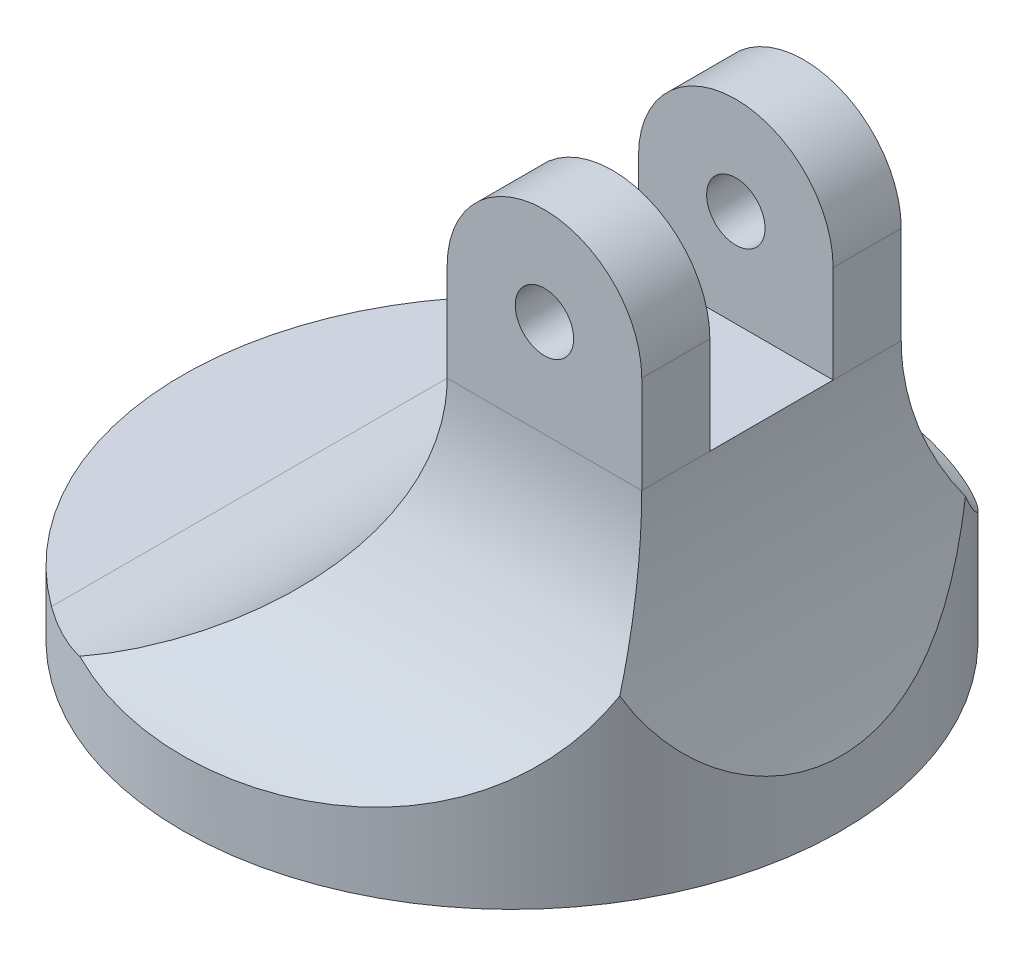
from build123d import *

# Parameters (mm, degrees)
SKETCH1_R               = 25.4
BASE_DEPTH              = 25
SKETCH3_OUTSIDE_W       = 68.014
SKETCH3_OUTSIDE_H       = 42.214
CUT_EXTRUDE1_DEPTH      = 26.4
CUT_EXTRUDE1_DEPTH_BACK = 26.4
SKETCH4_OUTSIDE_W       = 68.014
SKETCH4_OUTSIDE_H       = 42.214
CUT_EXTRUDE2_DEPTH      = 26.4000001
CUT_EXTRUDE2_DEPTH_BACK = 26.4000001
SKETCH5_R               = 2.25
CUT_EXTRUDE3_DEPTH      = 26.0000001
SKETCH6_R               = 4
CUT_EXTRUDE4_DEPTH      = 20
SKETCH7_W               = 15
SKETCH7_H               = 20
ARM_BASE_DEPTH          = 15
SKETCH8_R               = 2.25
ARM_HOLE_DEPTH          = 36.4000001
SKETCH9_W               = 9.5
SKETCH9_H               = 15
CUT_EXTRUDE7_DEPTH      = 46.4000001


with BuildPart() as part:
    # Sketch1 → base (new body)
    with BuildSketch(Plane(origin=(0, 0, 0), x_dir=(1, 0, 0), z_dir=(0, 1, 0))):
        Circle(SKETCH1_R)
    extrude(amount=BASE_DEPTH)

    # Sketch3 outside → Cut-Extrude1 (cut, two sides)
    with BuildSketch(Plane.XY) as cut_extrude1_sk:
        with Locations((0, 12.5)):
            Rectangle(SKETCH3_OUTSIDE_W, SKETCH3_OUTSIDE_H)
        with BuildLine():
            Line((5, 25), (20, 25))
            ThreePointArc((20, 25), (21.373745827, 14.641911373), (25.4, 5))
            Line((25.4, 5), (25.4, 0))
            Line((25.4, 0), (-25.4, 0))
            Line((-25.4, 0), (-25.4, 5))
            Line((-25.4, 5), (-15, 5))
            ThreePointArc((-15, 5), (-0.857864376, 10.857864376), (5, 25))
        make_face(mode=Mode.SUBTRACT)
    extrude(amount=CUT_EXTRUDE1_DEPTH, mode=Mode.SUBTRACT)
    extrude(cut_extrude1_sk.sketch, amount=-CUT_EXTRUDE1_DEPTH_BACK, mode=Mode.SUBTRACT)

    # Sketch4 outside → Cut-Extrude2 (cut, two sides)
    with BuildSketch(Plane(origin=(0, 0, 0), x_dir=(0, 0, -1), z_dir=(1, 0, 0))) as cut_extrude2_sk:
        with Locations((0, 12.5)):
            Rectangle(SKETCH4_OUTSIDE_W, SKETCH4_OUTSIDE_H)
        with BuildLine():
            Line((-25.4, 5), (-25.4, 0))
            Line((-25.4, 0), (25.4, 0))
            Line((25.4, 0), (25.4, 5))
            ThreePointArc((25.4, 5), (14.296085426, 12.378985778), (10, 25))
            Line((10, 25), (-10, 25))
            ThreePointArc((-10, 25), (-14.296085426, 12.378985778), (-25.4, 5))
        make_face(mode=Mode.SUBTRACT)
    extrude(amount=CUT_EXTRUDE2_DEPTH, mode=Mode.SUBTRACT)
    extrude(cut_extrude2_sk.sketch, amount=-CUT_EXTRUDE2_DEPTH_BACK, mode=Mode.SUBTRACT)

    # Sketch5 → Cut-Extrude3 (cut, through all)
    with BuildSketch(Plane.XZ):
        Circle(SKETCH5_R)
    extrude(amount=-CUT_EXTRUDE3_DEPTH, mode=Mode.SUBTRACT)

    # Sketch6 → Cut-Extrude4 (cut)
    with BuildSketch(Plane(origin=(0, 25, 0), x_dir=(1, 0, 0), z_dir=(0, 1, 0))):
        Circle(SKETCH6_R)
    extrude(amount=-CUT_EXTRUDE4_DEPTH, mode=Mode.SUBTRACT)

    # Sketch7 → arm base (add)
    with BuildSketch(Plane(origin=(0, 25, 0), x_dir=(1, 0, 0), z_dir=(0, 1, 0))):
        with Locations((12.5, 0)):
            Rectangle(SKETCH7_W, SKETCH7_H)
    extrude(amount=ARM_BASE_DEPTH)

    # Sketch8 → arm hole (cut, through all)
    with BuildSketch(Plane(origin=(0, 0, -10), x_dir=(-1, 0, 0), z_dir=(0, 0, -1))):
        with BuildLine():
            ThreePointArc((-12.5, 40), (-7.196699141, 37.803300859), (-5, 32.5))
            Line((-5, 32.5), (-5, 40))
            Line((-5, 40), (-12.5, 40))
        make_face()
        with BuildLine():
            ThreePointArc((-20, 32.5), (-17.803300859, 37.803300859), (-12.5, 40))
            Line((-12.5, 40), (-20, 40))
            Line((-20, 40), (-20, 32.5))
        make_face()
        with Locations((-12.5, 32.5)):
            Circle(SKETCH8_R)
    extrude(amount=-ARM_HOLE_DEPTH, mode=Mode.SUBTRACT)

    # Sketch9 → Cut-Extrude7 (cut, through all)
    with BuildSketch(Plane(origin=(20, 0, 0), x_dir=(0, 0, -1), z_dir=(1, 0, 0))):
        with Locations((0, 32.5)):
            Rectangle(SKETCH9_W, SKETCH9_H)
    extrude(amount=-CUT_EXTRUDE7_DEPTH, mode=Mode.SUBTRACT)


solid = part.part
